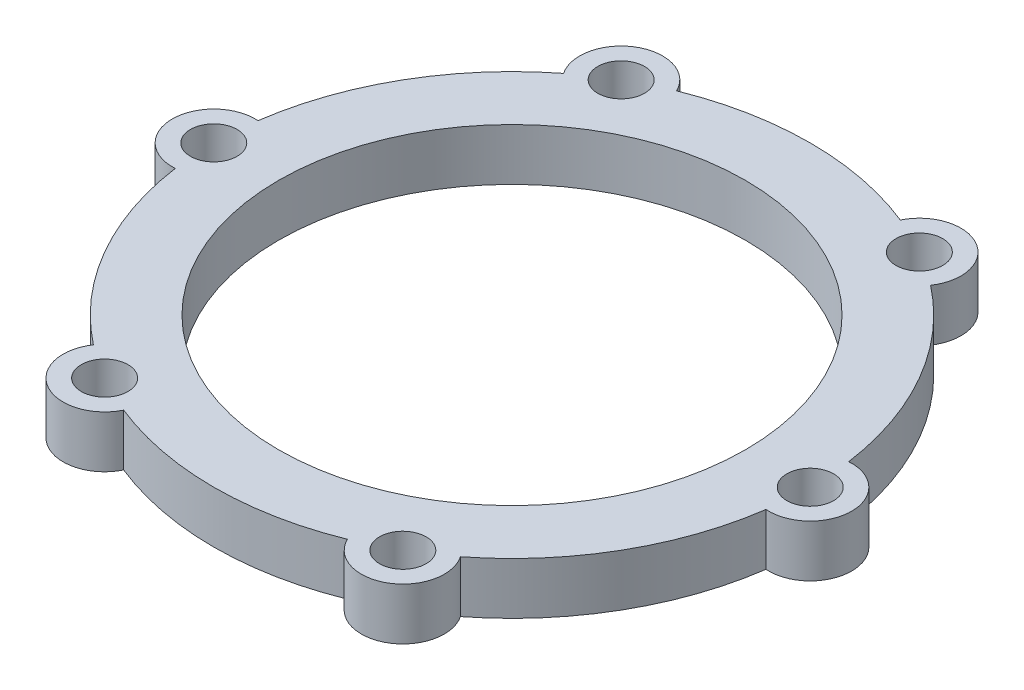
from build123d import *

# Parameters (mm, degrees)
SKETCH2_R           = 45
SKETCH2_R_2         = 4.5
BOSS_EXTRUDE1_DEPTH = 10


with BuildPart() as part:
    # Sketch2 → Boss-Extrude1 (new body)
    with BuildSketch(Plane(origin=(0, 0, 0), x_dir=(1, 0, 0), z_dir=(0, 1, 0))):
        with BuildLine():
            ThreePointArc((56.943478261, 7.980619246), (49.796460718, 28.75), (35.383158136, 45.324189131))
            ThreePointArc((35.383158136, 45.324189131), (32.75, 56.724663948), (21.560320125, 53.304808377))
            ThreePointArc((21.560320125, 53.304808377), (0, 57.5), (-21.560320125, 53.304808377))
            ThreePointArc((-21.560320125, 53.304808377), (-32.75, 56.724663948), (-35.383158136, 45.324189131))
            ThreePointArc((-35.383158136, 45.324189131), (-49.796460718, 28.75), (-56.943478261, 7.980619246))
            ThreePointArc((-56.943478261, 7.980619246), (-65.5, 0), (-56.943478261, -7.980619246))
            ThreePointArc((-56.943478261, -7.980619246), (-49.796460718, -28.75), (-35.383158136, -45.324189131))
            ThreePointArc((-35.383158136, -45.324189131), (-32.75, -56.724663948), (-21.560320125, -53.304808377))
            ThreePointArc((-21.560320125, -53.304808377), (0, -57.5), (21.560320125, -53.304808377))
            ThreePointArc((21.560320125, -53.304808377), (32.75, -56.724663948), (35.383158136, -45.324189131))
            ThreePointArc((35.383158136, -45.324189131), (49.796460718, -28.75), (56.943478261, -7.980619246))
            ThreePointArc((56.943478261, -7.980619246), (65.5, 0), (56.943478261, 7.980619246))
        make_face()
        Circle(SKETCH2_R, mode=Mode.SUBTRACT)
        with Locations((28.75, 49.796460718)):
            Circle(SKETCH2_R_2, mode=Mode.SUBTRACT)
        with Locations((-28.75, 49.796460718)):
            Circle(SKETCH2_R_2, mode=Mode.SUBTRACT)
        with Locations((57.5, 0)):
            Circle(SKETCH2_R_2, mode=Mode.SUBTRACT)
        with Locations((-57.5, 0)):
            Circle(SKETCH2_R_2, mode=Mode.SUBTRACT)
        with Locations((28.75, -49.796460718)):
            Circle(SKETCH2_R_2, mode=Mode.SUBTRACT)
        with Locations((-28.75, -49.796460718)):
            Circle(SKETCH2_R_2, mode=Mode.SUBTRACT)
    extrude(amount=BOSS_EXTRUDE1_DEPTH)


solid = part.part
